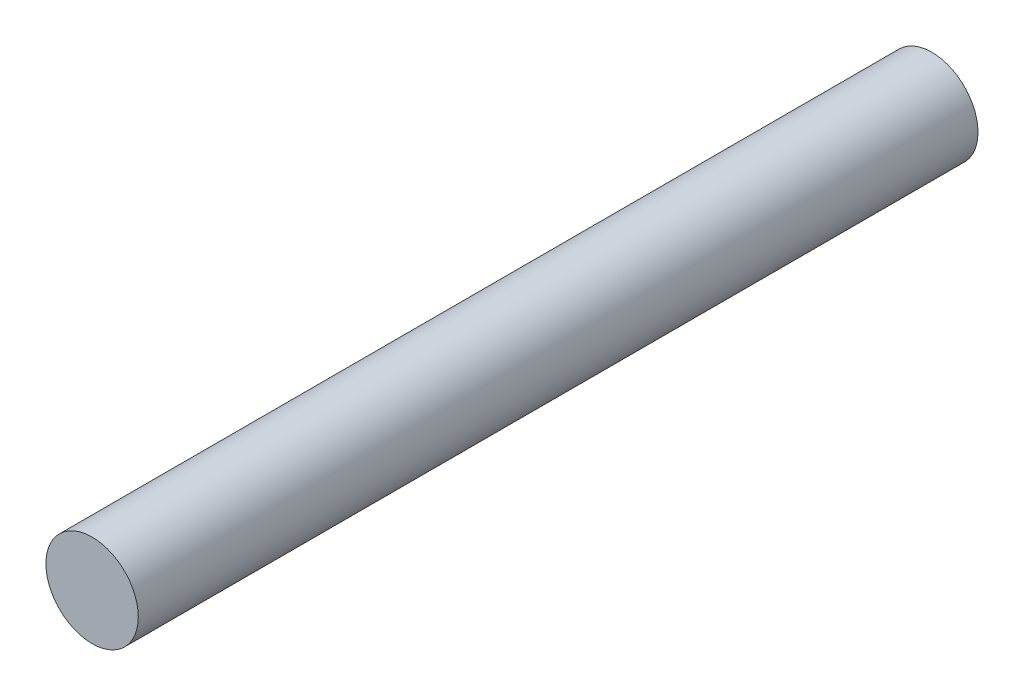
from build123d import *

# Parameters (mm, degrees)
SKICA1_R                = 1.65
P_IDAT_VYSUNUT_M1_DEPTH = 30


with BuildPart() as part:
    # Skica1 → Přidat vysunutím1 (new body)
    with BuildSketch(Plane.XY):
        Circle(SKICA1_R)
    extrude(amount=P_IDAT_VYSUNUT_M1_DEPTH)


solid = part.part
